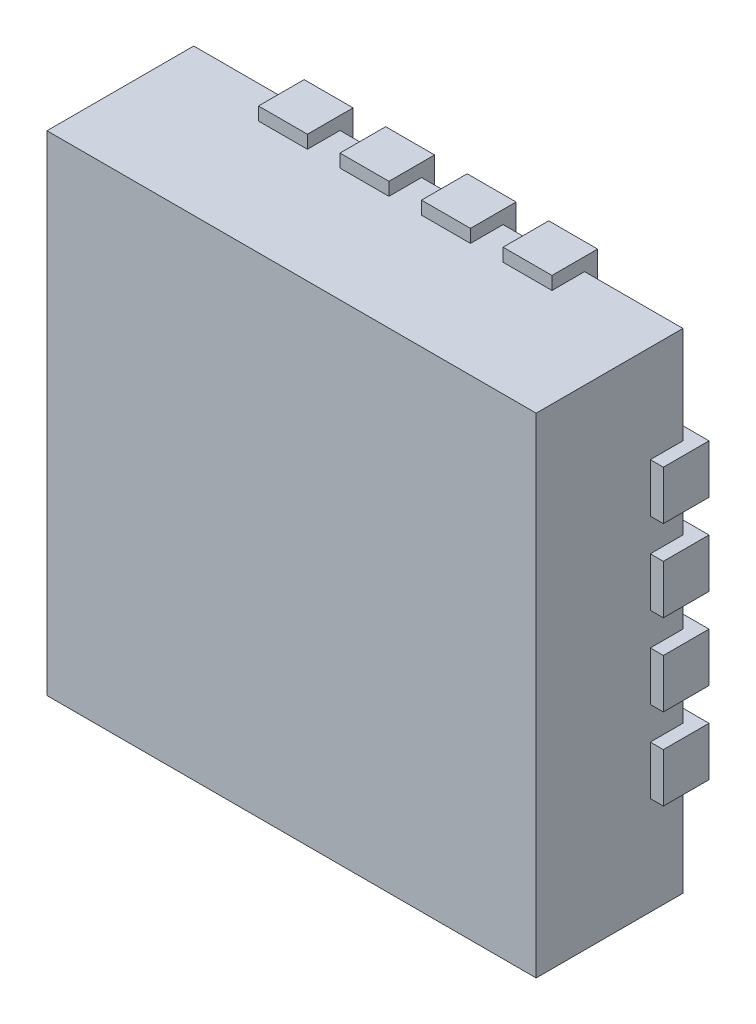
from build123d import *

# Parameters (mm, degrees)
SKETCH1_W             = 3
SKETCH1_H             = 3
BOSS_EXTRUDE1_DEPTH   = 0.9
BOSS_EXTRUDE2_DEPTH   = 0.08
BOSS_EXTRUDE2_2_DEPTH = 0.08
BOSS_EXTRUDE2_3_DEPTH = 0.08
BOSS_EXTRUDE2_4_DEPTH = 0.08
SKETCH3_W             = 0.3
SKETCH3_H             = 0.08
BOSS_EXTRUDE3_DEPTH   = 0.2
CIRPATTERN1_COUNT     = 4


with BuildPart() as part:
    # Sketch1 → Boss-Extrude1 (new body)
    with BuildSketch(Plane.XY):
        with Locations((1.5, 1.5)):
            Rectangle(SKETCH1_W, SKETCH1_H)
    extrude(amount=BOSS_EXTRUDE1_DEPTH)



with BuildPart() as body_2:
    # Sketch2 → Boss-Extrude2 (new body)
    with BuildSketch(Plane(origin=(0, 0, 0), x_dir=(-1, 0, 0), z_dir=(0, 0, -1))):
        with BuildLine():
            Line((-1.397, 3.08), (-1.097, 3.08))
            Line((-1.097, 3.08), (-1.097, 2.849999966))
            ThreePointArc((-1.097, 2.849999966), (-1.247, 2.7), (-1.397, 2.849999966))
            Line((-1.397, 2.849999966), (-1.397, 3.08))
        make_face()
    boss_extrude2 = extrude(amount=BOSS_EXTRUDE2_DEPTH)


with BuildPart() as body_3:
    # Sketch2 → Boss-Extrude2 2 (new body)
    with BuildSketch(Plane(origin=(0, 0, 0), x_dir=(-1, 0, 0), z_dir=(0, 0, -1))):
        with BuildLine():
            Line((-0.897, 3.08), (-0.597, 3.08))
            Line((-0.597, 3.08), (-0.597, 2.849999966))
            ThreePointArc((-0.597, 2.849999966), (-0.747, 2.7), (-0.897, 2.849999966))
            Line((-0.897, 2.849999966), (-0.897, 3.08))
        make_face()
    boss_extrude2_2 = extrude(amount=BOSS_EXTRUDE2_2_DEPTH)


with BuildPart() as body_4:
    # Sketch2 → Boss-Extrude2 3 (new body)
    with BuildSketch(Plane(origin=(0, 0, 0), x_dir=(-1, 0, 0), z_dir=(0, 0, -1))):
        with BuildLine():
            Line((-1.897, 3.08), (-1.597, 3.08))
            Line((-1.597, 3.08), (-1.597, 2.849999966))
            ThreePointArc((-1.597, 2.849999966), (-1.747, 2.7), (-1.897, 2.849999966))
            Line((-1.897, 2.849999966), (-1.897, 3.08))
        make_face()
    boss_extrude2_3 = extrude(amount=BOSS_EXTRUDE2_3_DEPTH)


with BuildPart() as body_5:
    # Sketch2 → Boss-Extrude2 4 (new body)
    with BuildSketch(Plane(origin=(0, 0, 0), x_dir=(-1, 0, 0), z_dir=(0, 0, -1))):
        with BuildLine():
            Line((-2.397, 3.08), (-2.097, 3.08))
            Line((-2.097, 3.08), (-2.097, 2.849999966))
            ThreePointArc((-2.097, 2.849999966), (-2.247, 2.7), (-2.397, 2.849999966))
            Line((-2.397, 2.849999966), (-2.397, 3.08))
        make_face()
    boss_extrude2_4 = extrude(amount=BOSS_EXTRUDE2_4_DEPTH)


with BuildPart() as part_1:
    add(part.part)

    add(body_2.part)  # Boss-Extrude3 merges body 2

    add(body_3.part)  # Boss-Extrude3 merges body 3

    add(body_4.part)  # Boss-Extrude3 merges body 4

    add(body_5.part)  # Boss-Extrude3 merges body 5
    # Sketch3 → Boss-Extrude3 (add)
    with BuildSketch(Plane.XY):
        with Locations((0.747, 3.04)):
            Rectangle(SKETCH3_W, SKETCH3_H)
        with Locations((1.247, 3.04)):
            Rectangle(SKETCH3_W, SKETCH3_H)
        with Locations((1.747, 3.04)):
            Rectangle(SKETCH3_W, SKETCH3_H)
        with Locations((2.247, 3.04)):
            Rectangle(SKETCH3_W, SKETCH3_H)
    boss_extrude3 = extrude(amount=BOSS_EXTRUDE3_DEPTH)

    # CirPattern1: Boss-Extrude2, Boss-Extrude2 2, Boss-Extrude2 3, Boss-Extrude2 4, Boss-Extrude3 ×4 about axis
    cirpattern1_axis = Axis((1.5, 1.5, -0.045), (0, 0, 1))
    add([boss_extrude2.rotate(cirpattern1_axis, i * 360 / CIRPATTERN1_COUNT) for i in range(1, CIRPATTERN1_COUNT)])
    add([boss_extrude2_2.rotate(cirpattern1_axis, i * 360 / CIRPATTERN1_COUNT) for i in range(1, CIRPATTERN1_COUNT)])
    add([boss_extrude2_3.rotate(cirpattern1_axis, i * 360 / CIRPATTERN1_COUNT) for i in range(1, CIRPATTERN1_COUNT)])
    add([boss_extrude2_4.rotate(cirpattern1_axis, i * 360 / CIRPATTERN1_COUNT) for i in range(1, CIRPATTERN1_COUNT)])
    add([boss_extrude3.rotate(cirpattern1_axis, i * 360 / CIRPATTERN1_COUNT) for i in range(1, CIRPATTERN1_COUNT)])


solid = part_1.part
